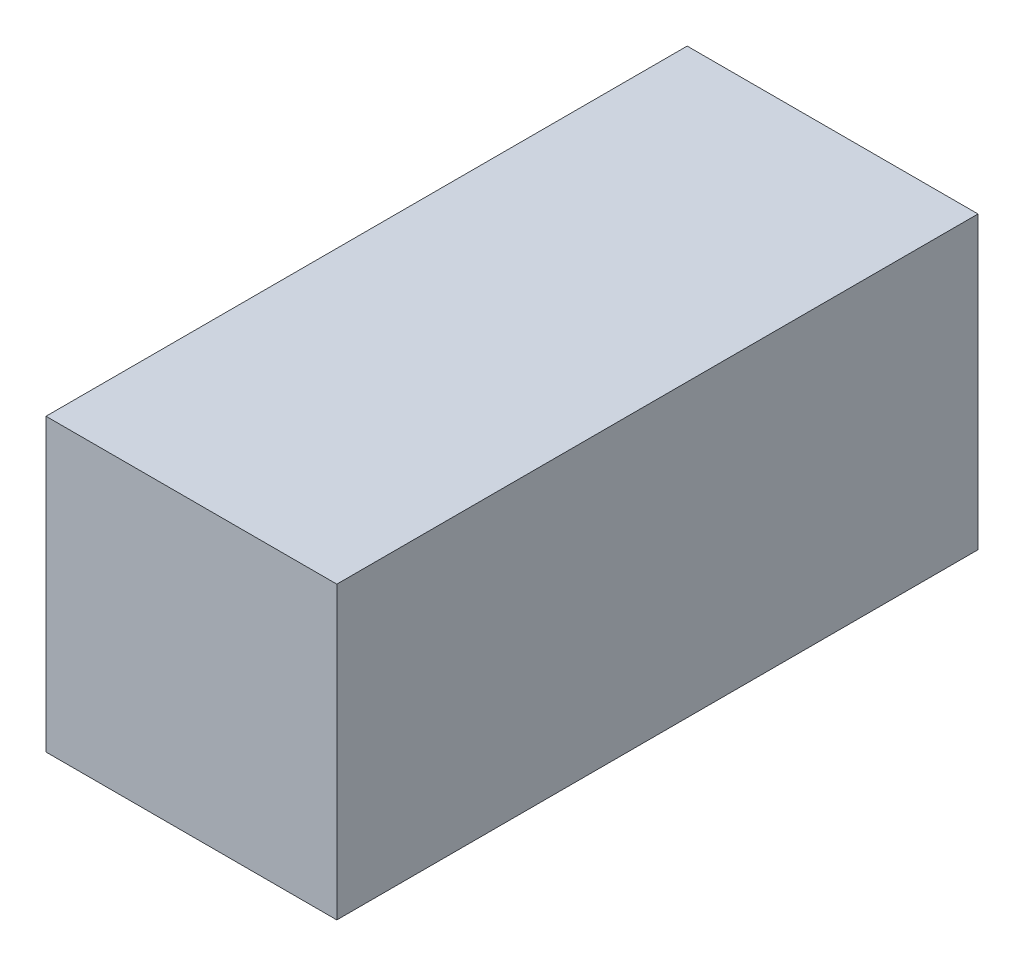
from build123d import *

# Parameters (mm, degrees)
CROQUIS1_W              = 63.5
CROQUIS1_H              = 63.5
CROQUIS1_W_2            = 59.7
CROQUIS1_H_2            = 59.7
SALIENTE_EXTRUIR1_DEPTH = 140
CROQUIS2_W              = 59.7
CROQUIS2_H              = 59.7
SALIENTE_EXTRUIR2_DEPTH = 1.9
CROQUIS3_W              = 59.7
CROQUIS3_H              = 59.7
SALIENTE_EXTRUIR3_DEPTH = 1.9


with BuildPart() as part:
    # Croquis1 → Saliente-Extruir1 (new body)
    with BuildSketch(Plane.XY):
        with Locations((31.75, -31.75)):
            Rectangle(CROQUIS1_W, CROQUIS1_H)
        with Locations((31.75, -31.75)):
            Rectangle(CROQUIS1_W_2, CROQUIS1_H_2, mode=Mode.SUBTRACT)
    extrude(amount=SALIENTE_EXTRUIR1_DEPTH)

    # Croquis2 → Saliente-Extruir2 (add)
    with BuildSketch(Plane.XY.offset(140)):
        with Locations((31.75, -31.75)):
            Rectangle(CROQUIS2_W, CROQUIS2_H)
    extrude(amount=-SALIENTE_EXTRUIR2_DEPTH)

    # Croquis3 → Saliente-Extruir3 (add)
    with BuildSketch(Plane(origin=(0, 0, 0), x_dir=(-1, 0, 0), z_dir=(0, 0, -1))):
        with Locations((-31.75, -31.75)):
            Rectangle(CROQUIS3_W, CROQUIS3_H)
    extrude(amount=-SALIENTE_EXTRUIR3_DEPTH)


solid = part.part
